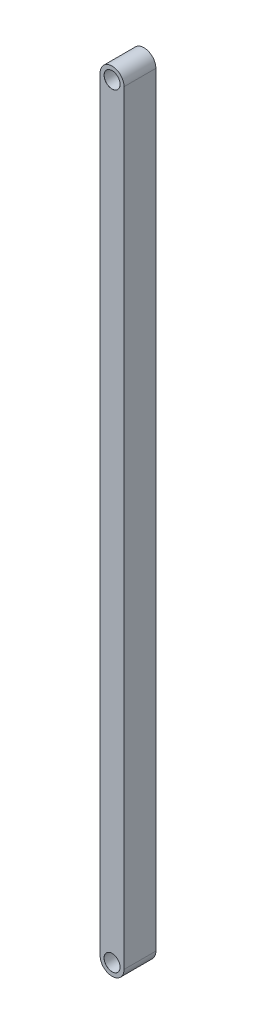
from build123d import *

# Parameters (mm, degrees)
BOSS_EXTRUDE1_DEPTH              = 20
F_10_0MM_DOWEL_HOLE1_D           = 10
F_10_0MM_DOWEL_HOLE1_CSINK_D     = 10.05
F_10_0MM_DOWEL_HOLE1_CSINK_ANGLE = 90


with BuildPart() as part:
    # Sketch2 → Boss-Extrude1 (new body)
    with BuildSketch(Plane.XY):
        with BuildLine():
            Line((-15, -240), (-15, 240))
            ThreePointArc((-15, 240), (-7.5, 247.5), (0, 240))
            Line((0, 240), (0, -240))
            ThreePointArc((0, -240), (-7.5, -247.5), (-15, -240))
        make_face()
    extrude(amount=BOSS_EXTRUDE1_DEPTH)

    # Ø10.0mm Dowel Hole1 (through all)
    with Locations(Plane.XY.offset(20)):
        with Locations((-7.5, 240), (-7.5, -240)):
            CounterSinkHole(F_10_0MM_DOWEL_HOLE1_D / 2, F_10_0MM_DOWEL_HOLE1_CSINK_D / 2, counter_sink_angle=F_10_0MM_DOWEL_HOLE1_CSINK_ANGLE)


solid = part.part
